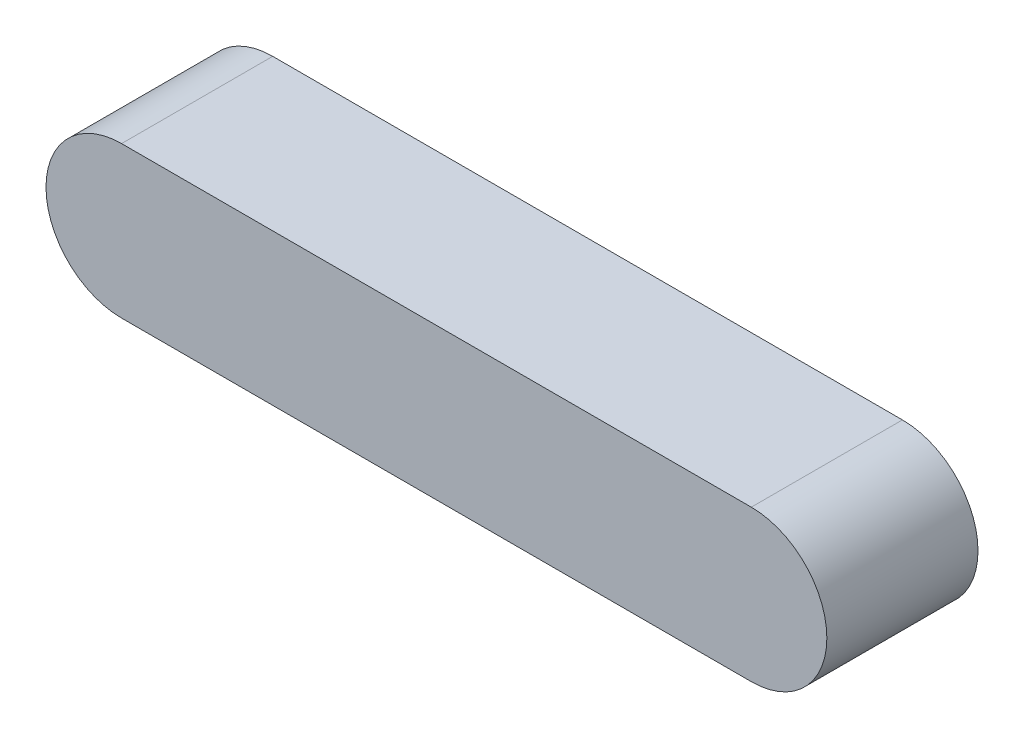
from build123d import *

# Parameters (mm, degrees)
EXTRUDE_1_DEPTH = 6


with BuildPart() as part:
    # Эскиз1 → Бобышка-Вытянуть1 (new body)
    with BuildSketch(Plane.XY):
        with BuildLine():
            Line((-12.5, 3), (12.5, 3))
            ThreePointArc((12.5, 3), (15.5, 0), (12.5, -3))
            Line((12.5, -3), (-12.5, -3))
            ThreePointArc((-12.5, -3), (-15.5, 0), (-12.5, 3))
        make_face()
    extrude(amount=-EXTRUDE_1_DEPTH)


solid = part.part
